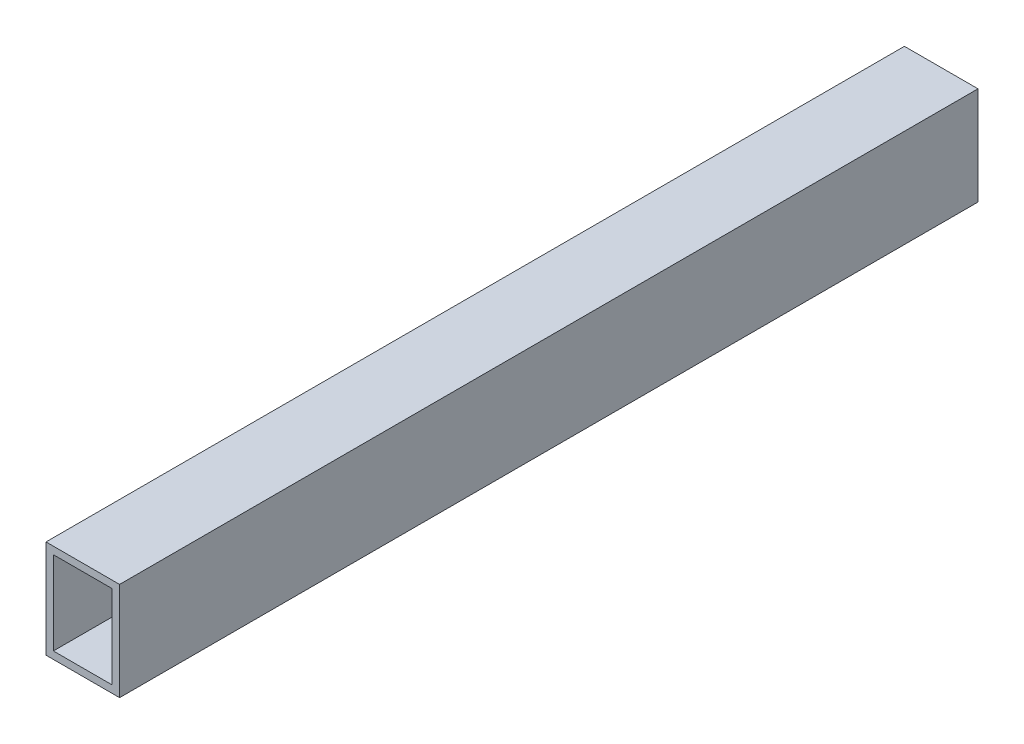
from build123d import *

# Parameters (mm, degrees)
CROQUIS1_W              = 350
CROQUIS1_H              = 40
SALIENTE_EXTRUIR1_DEPTH = 30
CROQUIS2_W              = 24
CROQUIS2_H              = 34
CORTAR_EXTRUIR1_DEPTH   = 890


with BuildPart() as part:
    # Croquis1 → Saliente-Extruir1 (new body)
    with BuildSketch(Plane(origin=(0, 0, 0), x_dir=(0, 0, -1), z_dir=(1, 0, 0))):
        Rectangle(CROQUIS1_W, CROQUIS1_H)
    extrude(amount=SALIENTE_EXTRUIR1_DEPTH)

    # Croquis2 → Cortar-Extruir1 (cut)
    with BuildSketch(Plane.XY.offset(175)):
        with Locations((15, 0)):
            Rectangle(CROQUIS2_W, CROQUIS2_H)
    extrude(amount=-CORTAR_EXTRUIR1_DEPTH, mode=Mode.SUBTRACT)


solid = part.part
